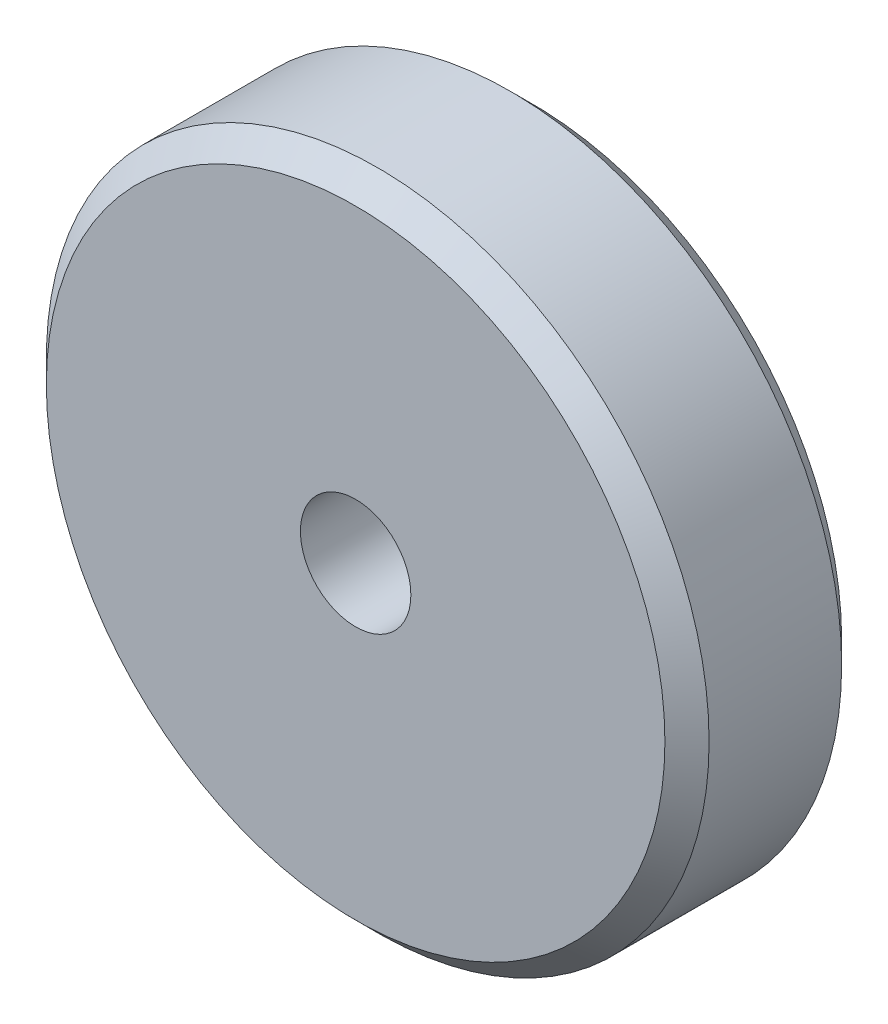
from build123d import *

# Parameters (mm, degrees)
SKETCH1_R           = 15
SKETCH1_R_2         = 2.5
BOSS_EXTRUDE1_DEPTH = 8
CHAMFER1_SIZE       = 1


with BuildPart() as part:
    # Sketch1 → Boss-Extrude1 (new body)
    with BuildSketch(Plane.XY):
        Circle(SKETCH1_R)
        Circle(SKETCH1_R_2, mode=Mode.SUBTRACT)
    extrude(amount=BOSS_EXTRUDE1_DEPTH)

    # Chamfer1
    chamfer1_edges = [part.edges().sort_by_distance(p)[0] for p in [
        (-15, 0, 0),
        (-15, 0, 8),
    ]]
    chamfer(chamfer1_edges, length=CHAMFER1_SIZE)


solid = part.part
